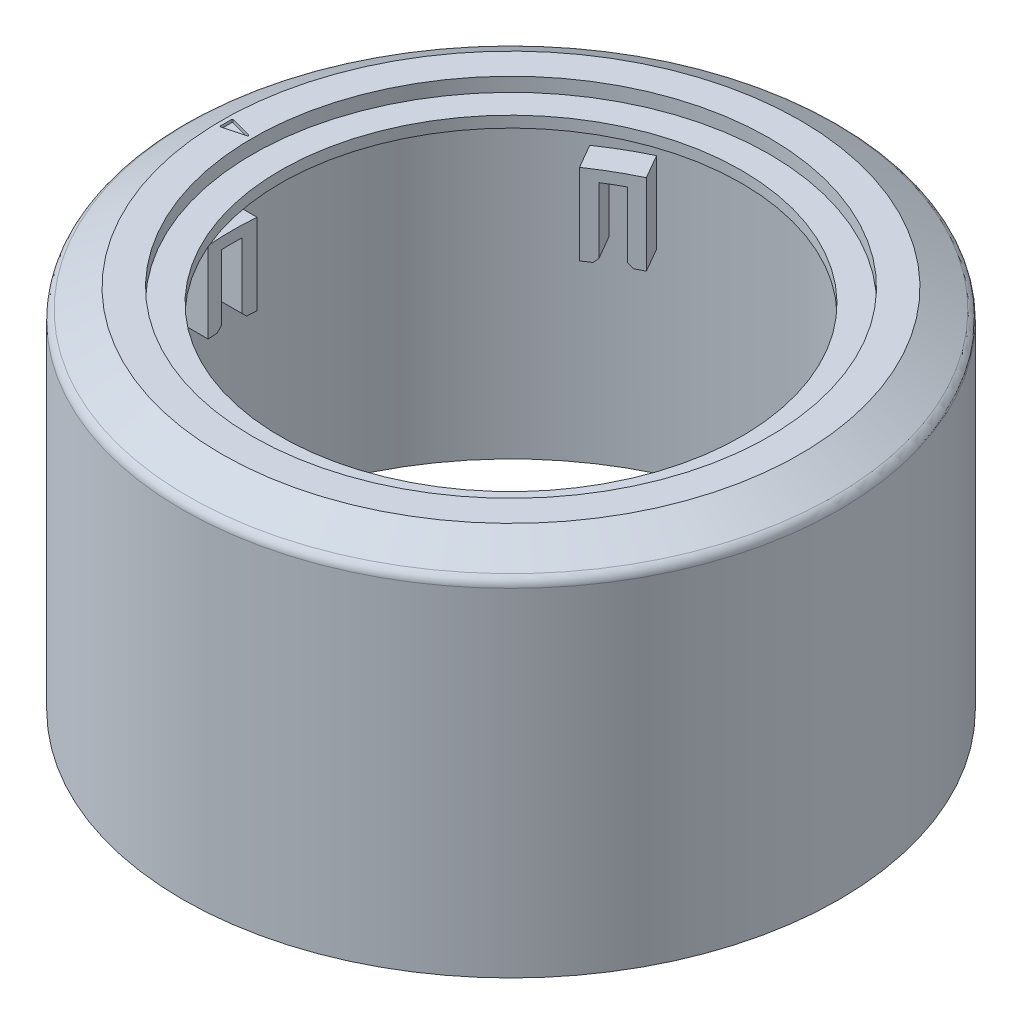
from build123d import *

# Parameters (mm, degrees)
EXTRUDE_5_REACH          = 62.717
EXTRUDE_5_START_RADIUS   = 22
EXTRUDE_5_END_RADIUS     = 22
PATTERN_CIRCULAR_2_COUNT = 6
CUT_EXTRUDE_1_DEPTH      = 0.2
FILLET_1_R               = 0.05
CHAMFER_1_SIZE           = 0.3


with BuildPart() as part:
    # 草图1 → 旋转1 (revolve)
    with BuildSketch(Plane.XY, mode=Mode.PRIVATE) as revolve_1_sk:
        with BuildLine():
            Line((-22, 0), (-23.5, 0))
            Line((-23.5, 0), (-23.5, 24.150257739))
            ThreePointArc((-23.5, 24.150257739), (-23.399484522, 24.525386608), (-23.124871131, 24.8))
            Line((-23.124871131, 24.8), (-20.7, 26.2))
            Line((-20.7, 26.2), (-18.5, 26.2))
            Line((-18.5, 26.2), (-18.5, 25.2))
            Line((-18.5, 25.2), (-16.5, 25.2))
            Line((-16.5, 25.2), (-16.5, 24.4))
            Line((-16.5, 24.4), (-22, 24.4))
            Line((-22, 24.4), (-22, 0))
        make_face()
    revolve(revolve_1_sk.sketch.rotate(Axis((0, 0, 0), (0, 1, 0)), 270), axis=Axis((0, 0, 0), (0, 1, 0)))

    # 凸台-拉伸5: from a cylinder face, 62.717 long prism both ways, kept between that surface and its translate by the depth
    extrude_5_start = Plane(origin=(0, 16.4, 0), z_dir=(0, -1, 0)) * Cylinder(EXTRUDE_5_START_RADIUS, 170.434, mode=Mode.PRIVATE)
    extrude_5_end = Plane(origin=(2, 16.4, 0), z_dir=(0, -1, 0)) * Cylinder(EXTRUDE_5_END_RADIUS, 170.434, mode=Mode.PRIVATE)
    # 草图5 → 凸台-拉伸5 (add, from a surface)
    with BuildSketch(Plane.ZY.offset(23.5), mode=Mode.PRIVATE) as extrude_5_sk1:
        Polygon((-0.75, 13.9), (-0.75, 18.9), (0.75, 18.9), (0.75, 13.9), (1.75, 13.9), (1.75, 19.7), (-1.75, 19.7), (-1.75, 13.9), align=None)
    extrude_5_tool1 = extrude(extrude_5_sk1.sketch, amount=EXTRUDE_5_REACH, both=True, mode=Mode.PRIVATE)
    extrude_5 = ((extrude_5_tool1 & extrude_5_start) - extrude_5_end).solids().sort_by_distance((-20.95875, 16.4, -0.817742))[0]
    add(extrude_5)

    # 阵列(圆周)2: 凸台-拉伸5 ×6 about axis
    pattern_circular_2_axis = Axis((0, 0, 0), (0, 1, 0))
    for i in range(1, PATTERN_CIRCULAR_2_COUNT):
        add(extrude_5.rotate(pattern_circular_2_axis, i * 360 / PATTERN_CIRCULAR_2_COUNT))

    # 草图6 → 切除-拉伸1 (cut)
    with BuildSketch(Plane(origin=(0, 26.2, 0), x_dir=(1, 0, 0), z_dir=(0, 1, 0))):
        Polygon((-20.4, 0.468911087), (-18.65, 0), (-20.4, -0.468911087), align=None)
    extrude(amount=-CUT_EXTRUDE_1_DEPTH, mode=Mode.SUBTRACT)

    # 圆角1
    fillet_1_edges = [part.edges().sort_by_distance(p)[0] for p in [
        (-20.4, 26.1, 0.468911087),
        (-20.4, 26.1, -0.468911087),
        (-18.65, 26.1, 0),
    ]]
    fillet(fillet_1_edges, radius=FILLET_1_R)

    # 倒角1
    chamfer_1_edges = [part.edges().sort_by_distance(p)[0] for p in [
        (11.143125149, 13.9, 17.800458913),
        (9.844087043, 13.9, 18.550458913),
        (-9.844087043, 13.9, 18.550458913),
        (-11.143125149, 13.9, 17.800458913),
        (-20.987212193, 13.9, 0.75),
        (-20.987212193, 13.9, -0.75),
        (-11.143125149, 13.9, -17.800458913),
        (-9.844087043, 13.9, -18.550458913),
        (9.844087043, 13.9, -18.550458913),
        (11.143125149, 13.9, -17.800458913),
        (20.987212193, 13.9, -0.75),
        (20.987212193, 13.9, 0.75),
    ]]
    chamfer(chamfer_1_edges, length=CHAMFER_1_SIZE)


solid = part.part
